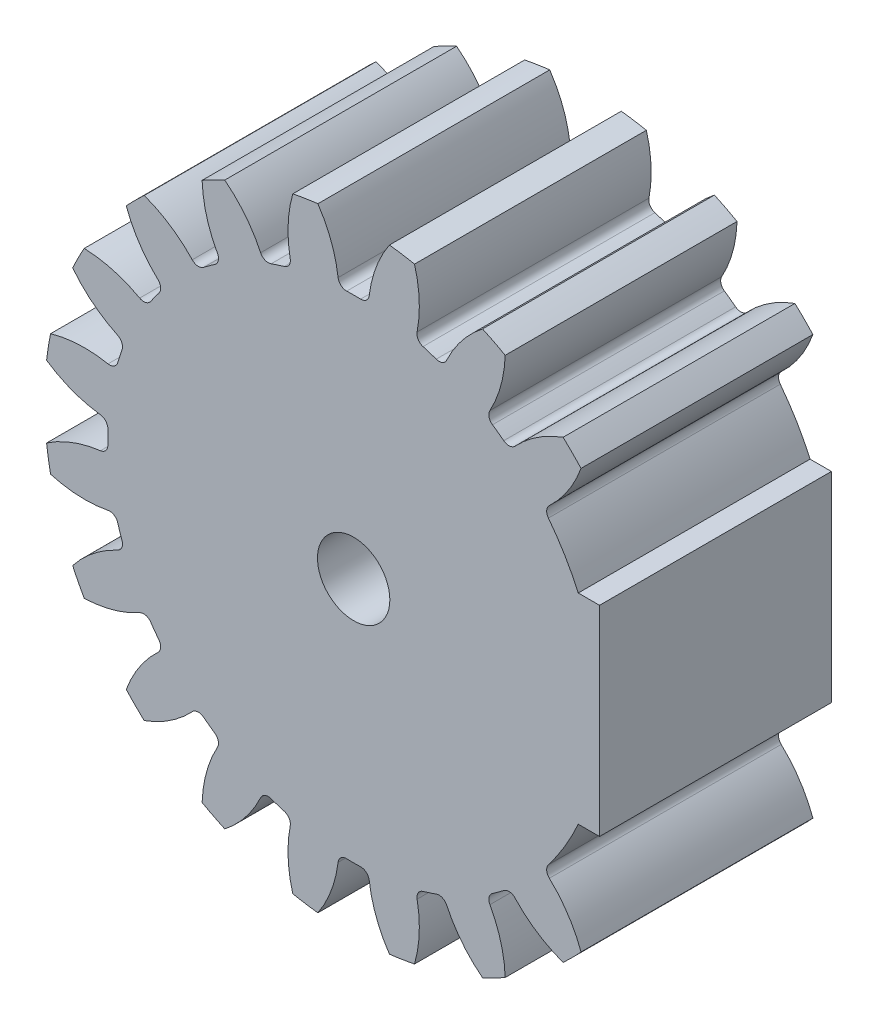
from build123d import *

# Parameters (mm, degrees)
SKBASE_R                                = 22
BASE_DEPTH                              = 8.25
TOOTHPROFILE_DEPTH                      = 9.25
FILLETTOOTHPROFILE_R                    = 0.6
CIRPATTERNTEETH_COUNT                   = 20
FILLETTOOTHPROFILE_OF_CIRPATTERNTEETH_R = 0.6
SKCHAVETA_R                             = 2.575
CHAVETA_DEPTH                           = 17.5000001
CUT_EXTRUDE1_DEPTH                      = 16.5
SKETCH8_W                               = 14.925
SKETCH8_H                               = 14.25
BOSS_EXTRUDE1_DEPTH                     = 16.5


with BuildPart() as part:
    # skBase → Base (new body, symmetric)
    with BuildSketch(Plane.XY):
        Circle(SKBASE_R)
    extrude(amount=BASE_DEPTH, both=True)

    # skToothProfile → ToothProfile (cut, symmetric)
    with BuildSketch(Plane.XY):
        with BuildLine():
            ThreePointArc((-1.056260379, 17.468094172), (-1.711312383, 20.303280592), (-3.25795804, 22.768085326))
            ThreePointArc((-3.25795804, 22.768085326), (0, 23), (3.25795804, 22.768085326))
            ThreePointArc((3.25795804, 22.768085326), (1.711312383, 20.303280592), (1.056260379, 17.468094172))
            ThreePointArc((1.056260379, 17.468094172), (0, 17.5), (-1.056260379, 17.468094172))
        make_face()
    toothprofile = extrude(amount=TOOTHPROFILE_DEPTH, both=True, mode=Mode.SUBTRACT)

    # FilletToothProfile
    fillettoothprofile_edges = [part.edges().sort_by_distance(p)[0] for p in [
        (-1.056260379, 17.468094172, 0),
        (1.056260379, 17.468094172, 0),
    ]]
    fillet(fillettoothprofile_edges, radius=FILLETTOOTHPROFILE_R)

    # CirPatternTeeth: ToothProfile ×20 about axis
    cirpatternteeth_axis = Axis((0, 0, 0), (0, 0, 1))
    for i in range(1, CIRPATTERNTEETH_COUNT):
        add(toothprofile.rotate(cirpatternteeth_axis, i * 360 / CIRPATTERNTEETH_COUNT), mode=Mode.SUBTRACT)

    # FilletToothProfile of CirPatternTeeth
    fillettoothprofile_of_cirpatternteeth_edges = [part.edges().sort_by_distance(p)[0] for p in [
        (-6.402501275, 16.286742382, 0),
        (-4.393374642, 16.939547198, 0),
        (-11.122020738, 13.511130771, 0),
        (-9.412955543, 14.752839318, 0),
        (-14.752839318, 9.412955543, 0),
        (-13.511130771, 11.122020738, 0),
        (-16.939547198, 4.393374642, 0),
        (-16.286742382, 6.402501275, 0),
        (-17.468094172, -1.056260379, 0),
        (-17.468094172, 1.056260379, 0),
        (-16.286742382, -6.402501275, 0),
        (-16.939547198, -4.393374642, 0),
        (-13.511130771, -11.122020738, 0),
        (-14.752839318, -9.412955543, 0),
        (-9.412955543, -14.752839318, 0),
        (-11.122020738, -13.511130771, 0),
        (-4.393374642, -16.939547198, 0),
        (-6.402501275, -16.286742382, 0),
        (1.056260379, -17.468094172, 0),
        (-1.056260379, -17.468094172, 0),
        (6.402501275, -16.286742382, 0),
        (4.393374642, -16.939547198, 0),
        (11.122020738, -13.511130771, 0),
        (9.412955543, -14.752839318, 0),
        (14.752839318, -9.412955543, 0),
        (13.511130771, -11.122020738, 0),
        (16.939547198, -4.393374642, 0),
        (16.286742382, -6.402501275, 0),
        (17.468094172, 1.056260379, 0),
        (17.468094172, -1.056260379, 0),
        (16.286742382, 6.402501275, 0),
        (16.939547198, 4.393374642, 0),
        (13.511130771, 11.122020738, 0),
        (14.752839318, 9.412955543, 0),
        (9.412955543, 14.752839318, 0),
        (11.122020738, 13.511130771, 0),
        (4.393374642, 16.939547198, 0),
        (6.402501275, 16.286742382, 0),
    ]]
    fillet(fillettoothprofile_of_cirpatternteeth_edges, radius=FILLETTOOTHPROFILE_OF_CIRPATTERNTEETH_R)

    # skChaveta → Chaveta (cut, through all)
    with BuildSketch(Plane.XY.offset(8.25)):
        Circle(SKCHAVETA_R)
    extrude(amount=-CHAVETA_DEPTH, mode=Mode.SUBTRACT)

    # Sketch7 → Cut-Extrude1 (cut)
    with BuildSketch(Plane(origin=(0, 0, -8.25), x_dir=(-1, 0, 0), z_dir=(0, 0, -1))):
        with BuildLine():
            ThreePointArc((-17.493007874, 0.494646854), (-17.28454596, 2.737603138), (-16.789693413, 4.935199602))
            ThreePointArc((-16.789693413, 4.935199602), (-17.05320753, 4.591987385), (-17.479060308, 4.515281924))
            ThreePointArc((-17.479060308, 4.515281924), (-19.535104209, 4.665405011), (-21.569390736, 4.331441248))
            ThreePointArc((-21.569390736, 4.331441248), (-21.729143493, 3.441558231), (-21.852198568, 2.545862871))
            ThreePointArc((-21.852198568, 2.545862871), (-20.020677589, 1.599615351), (-18.018873054, 1.107038384))
            ThreePointArc((-18.018873054, 1.107038384), (-17.637566285, 0.90249141), (-17.493007874, 0.494646854))
        make_face()
        with BuildLine():
            ThreePointArc((-17.479060308, -4.515281924), (-17.05320753, -4.591987385), (-16.789693413, -4.935199602))
            ThreePointArc((-16.789693413, -4.935199602), (-17.28454596, -2.737603138), (-17.493007874, -0.494646854))
            ThreePointArc((-17.493007874, -0.494646854), (-17.637566285, -0.90249141), (-18.018873054, -1.107038384))
            ThreePointArc((-18.018873054, -1.107038384), (-20.020677589, -1.599615351), (-21.852198568, -2.545862871))
            ThreePointArc((-21.852198568, -2.545862871), (-21.729143493, -3.441558231), (-21.569390736, -4.331441248))
            ThreePointArc((-21.569390736, -4.331441248), (-19.535104209, -4.665405011), (-17.479060308, -4.515281924))
        make_face()
        with BuildLine():
            ThreePointArc((-15.228275356, -9.695614978), (-14.799562005, -9.636970461), (-14.442886779, -9.881954336))
            ThreePointArc((-14.442886779, -9.881954336), (-15.592614173, -7.944833745), (-16.483984844, -5.87607383))
            ThreePointArc((-16.483984844, -5.87607383), (-16.495437164, -6.308628058), (-16.79487296, -6.620994062))
            ThreePointArc((-16.79487296, -6.620994062), (-18.546487554, -7.708054217), (-19.99596095, -9.173960195))
            ThreePointArc((-19.99596095, -9.173960195), (-19.602143532, -9.987790994), (-19.175220656, -10.78475372))
            ThreePointArc((-19.175220656, -10.78475372), (-17.137298721, -10.473743024), (-15.228275356, -9.695614978))
        make_face()
        with BuildLine():
            ThreePointArc((-16.483984844, 5.87607383), (-15.592614173, 7.944833745), (-14.442886779, 9.881954336))
            ThreePointArc((-14.442886779, 9.881954336), (-14.799562005, 9.636970461), (-15.228275356, 9.695614978))
            ThreePointArc((-15.228275356, 9.695614978), (-17.137298721, 10.473743024), (-19.175220656, 10.78475372))
            ThreePointArc((-19.175220656, 10.78475372), (-19.602143532, 9.987790994), (-19.99596095, 9.173960195))
            ThreePointArc((-19.99596095, 9.173960195), (-18.546487554, 7.708054217), (-16.79487296, 6.620994062))
            ThreePointArc((-16.79487296, 6.620994062), (-16.495437164, 6.308628058), (-16.483984844, 5.87607383))
        make_face()
    extrude(amount=-CUT_EXTRUDE1_DEPTH, mode=Mode.SUBTRACT)

    # Sketch8 → Boss-Extrude1 (add)
    with BuildSketch(Plane(origin=(0, 0, -8.25), x_dir=(-1, 0, 0), z_dir=(0, 0, -1))):
        with Locations((-10.0375, 0)):
            Rectangle(SKETCH8_W, SKETCH8_H)
    extrude(amount=-BOSS_EXTRUDE1_DEPTH)


solid = part.part
